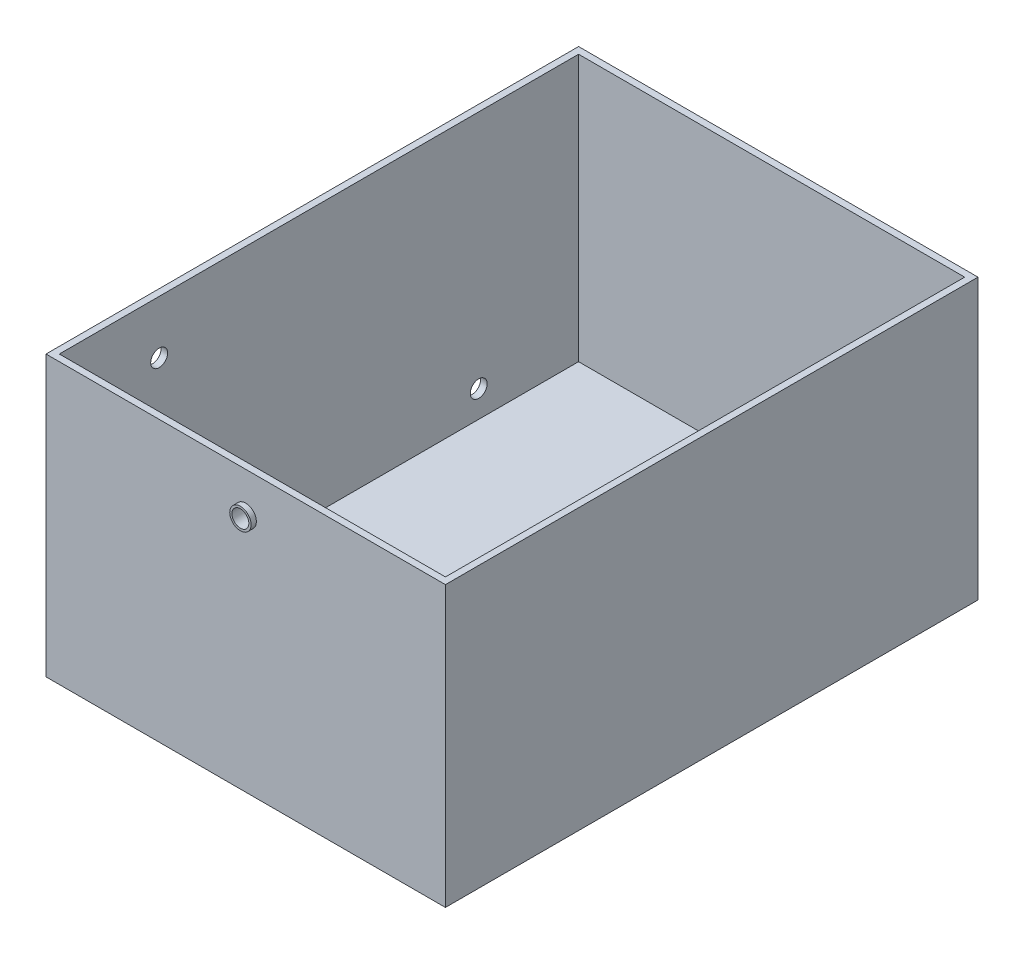
from build123d import *

# Parameters (mm, degrees)
SKETCH1_W           = 150
SKETCH1_H           = 200
BOSS_EXTRUDE1_DEPTH = 5
SKETCH2_W           = 150
SKETCH2_H           = 200
SKETCH2_W_2         = 145
SKETCH2_H_2         = 195
BOSS_EXTRUDE2_DEPTH = 100
SKETCH3_R           = 3.175
CUT_EXTRUDE1_DEPTH  = 50
SKETCH4_R           = 4
SKETCH4_R_2         = 3.175
BOSS_EXTRUDE3_DEPTH = 2
SKETCH5_R           = 3.175
CUT_EXTRUDE2_DEPTH  = 14
SKETCH6_R           = 4
SKETCH6_R_2         = 3.175
BOSS_EXTRUDE4_DEPTH = 2
SKETCH7_R           = 3.174999996
SKETCH7_R_2         = 3.175
CUT_EXTRUDE3_DEPTH  = 10


with BuildPart() as part:
    # Sketch1 → Boss-Extrude1 (new body)
    with BuildSketch(Plane(origin=(0, 0, 0), x_dir=(1, 0, 0), z_dir=(0, 1, 0))):
        Rectangle(SKETCH1_W, SKETCH1_H)
    extrude(amount=BOSS_EXTRUDE1_DEPTH)

    # Sketch2 → Boss-Extrude2 (add)
    with BuildSketch(Plane(origin=(0, 5, 0), x_dir=(1, 0, 0), z_dir=(0, 1, 0))):
        Rectangle(SKETCH2_W, SKETCH2_H)
        Rectangle(SKETCH2_W_2, SKETCH2_H_2, mode=Mode.SUBTRACT)
    extrude(amount=BOSS_EXTRUDE2_DEPTH)

    # Sketch3 → Cut-Extrude1 (cut)
    with BuildSketch(Plane.XY.offset(100)):
        with Locations((0, 90)):
            Circle(SKETCH3_R)
    extrude(amount=-CUT_EXTRUDE1_DEPTH, mode=Mode.SUBTRACT)

    # Sketch4 → Boss-Extrude3 (add)
    with BuildSketch(Plane.XY.offset(100)):
        with Locations((0, 90)):
            Circle(SKETCH4_R)
        with Locations((0, 90)):
            Circle(SKETCH4_R_2, mode=Mode.SUBTRACT)
    extrude(amount=BOSS_EXTRUDE3_DEPTH)

    # Sketch5 → Cut-Extrude2 (cut)
    with BuildSketch(Plane(origin=(0, 0, -100), x_dir=(-1, 0, 0), z_dir=(0, 0, -1))):
        with Locations((0, 10)):
            Circle(SKETCH5_R)
    extrude(amount=-CUT_EXTRUDE2_DEPTH, mode=Mode.SUBTRACT)

    # Sketch6 → Boss-Extrude4 (add)
    with BuildSketch(Plane(origin=(0, 0, -100), x_dir=(-1, 0, 0), z_dir=(0, 0, -1))):
        with Locations((0, 10)):
            Circle(SKETCH6_R)
        with Locations((0, 10)):
            Circle(SKETCH6_R_2, mode=Mode.SUBTRACT)
    extrude(amount=BOSS_EXTRUDE4_DEPTH)

    # Sketch7 → Cut-Extrude3 (cut)
    with BuildSketch(Plane.ZY.offset(75)):
        with Locations((-60, 15)):
            Circle(SKETCH7_R)
        with Locations((60, 85)):
            Circle(SKETCH7_R_2)
    extrude(amount=-CUT_EXTRUDE3_DEPTH, mode=Mode.SUBTRACT)


solid = part.part
